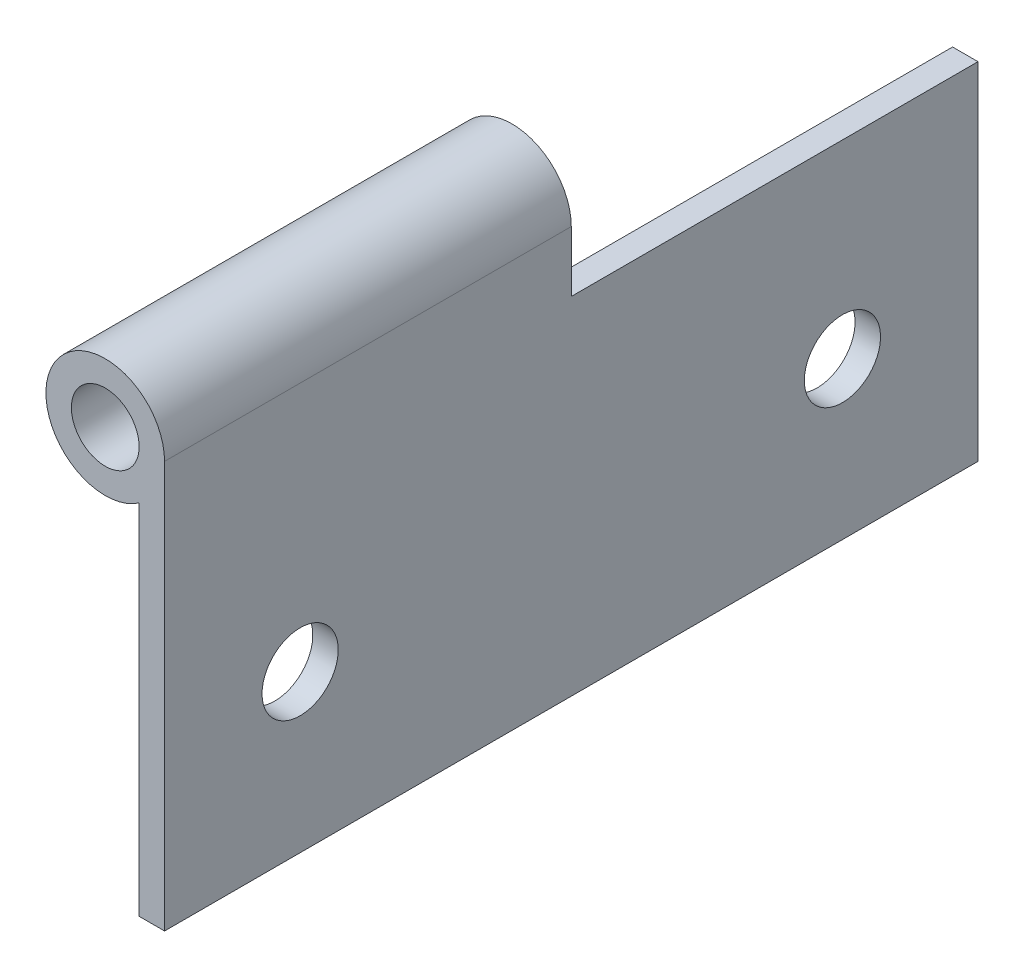
from build123d import *

# Parameters (mm, degrees)
SKETCH1_R          = 3.175
EXTRUDE1_DEPTH     = 38.1
SKETCH2_W          = 2.380423229
SKETCH2_H          = 32.427702335
EXTRUDE2_DEPTH     = 38.1
SKETCH3_R          = 3.5687
CUT_EXTRUDE1_DEPTH = 2.380423


with BuildPart() as part:
    # Sketch1 → Extrude1 (new body)
    with BuildSketch(Plane.XY):
        with BuildLine():
            Line((214.284444429, 56.4017138), (214.284444429, 94.5017138))
            ThreePointArc((214.284444429, 94.5017138), (203.802872025, 97.073311219), (211.9040212, 89.942543))
            Line((211.9040212, 89.942543), (211.9040212, 56.4017138))
            Line((211.9040212, 56.4017138), (214.284444429, 56.4017138))
        make_face()
        with Locations((208.728194429, 94.5017138)):
            Circle(SKETCH1_R, mode=Mode.SUBTRACT)
    extrude(amount=EXTRUDE1_DEPTH)

    # Sketch2 → Extrude2 (add)
    with BuildSketch(Plane(origin=(0, 0, 0), x_dir=(-1, 0, 0), z_dir=(0, 0, -1))):
        with Locations((-213.094232815, 72.615564968)):
            Rectangle(SKETCH2_W, SKETCH2_H)
    extrude(amount=EXTRUDE2_DEPTH)

    # Sketch3 → Cut-Extrude1 (cut)
    with BuildSketch(Plane.ZY.offset(-211.9040212)):
        with Locations((-25.4, 71.0829138)):
            Circle(SKETCH3_R)
        with Locations((25.4, 71.0829138)):
            Circle(SKETCH3_R)
    extrude(amount=-CUT_EXTRUDE1_DEPTH, mode=Mode.SUBTRACT)


solid = part.part
